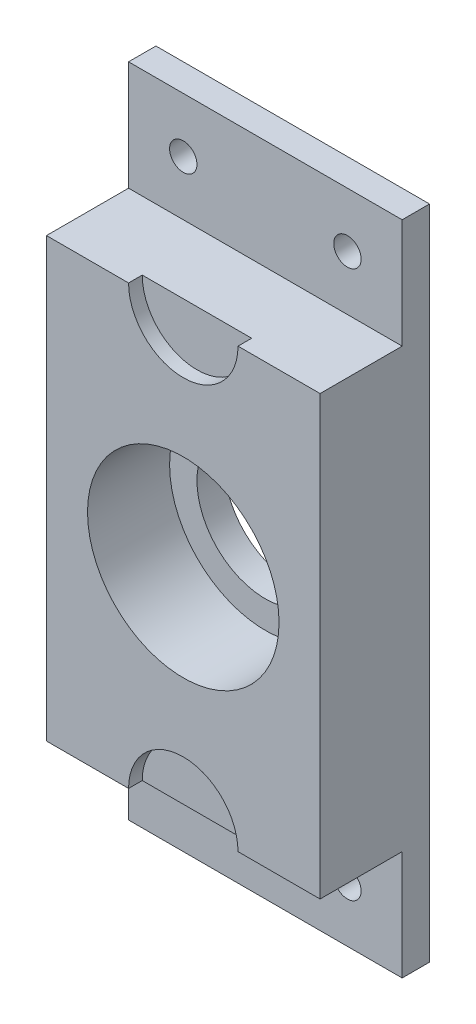
from build123d import *

# Parameters (mm, degrees)
BOSS_EXTRUDE1_DEPTH = 25.4
SKETCH2_W           = 63.5
SKETCH2_H           = 25.4
CUT_EXTRUDE1_DEPTH  = 19.05
SKETCH3_R           = 15.875
CUT_EXTRUDE4_DEPTH  = 26.4
SKETCH5_R           = 22.225
SKETCH5_R_2         = 15.875
CUT_EXTRUDE6_DEPTH  = 19.05
SKETCH6_R           = 12.7
CUT_EXTRUDE7_DEPTH  = 3.175
BOSS_EXTRUDE2_DEPTH = 25.4
SKETCH9_W           = 19.05
SKETCH9_H           = 3.556
BOSS_EXTRUDE4_DEPTH = 35.56


with BuildPart() as part:
    # Sketch1 → Boss-Extrude1 (new body)
    with BuildSketch(Plane.XY):
        with BuildLine():
            Line((-19.05, -66.675), (-19.05, -76.2))
            Line((-19.05, -76.2), (19.05, -76.2))
            Line((19.05, -76.2), (19.05, -66.675))
            ThreePointArc((19.05, -66.675), (16.80493597, -61.25493597), (22.225, -63.5))
            Line((22.225, -63.5), (31.75, -63.5))
            Line((31.75, -63.5), (31.75, 63.5))
            Line((31.75, 63.5), (22.225, 63.5))
            ThreePointArc((22.225, 63.5), (16.80493597, 61.25493597), (19.05, 66.675))
            Line((19.05, 66.675), (19.05, 76.2))
            Line((19.05, 76.2), (-19.05, 76.2))
            Line((-19.05, 76.2), (-19.05, 66.675))
            ThreePointArc((-19.05, 66.675), (-16.80493597, 65.74506403), (-15.875, 63.5))
            ThreePointArc((-15.875, 63.5), (-19.05, 60.325), (-22.225, 63.5))
            Line((-22.225, 63.5), (-31.75, 63.5))
            Line((-31.75, 63.5), (-31.75, -63.5))
            Line((-31.75, -63.5), (-22.225, -63.5))
            ThreePointArc((-22.225, -63.5), (-19.05, -60.325), (-15.875, -63.5))
            ThreePointArc((-15.875, -63.5), (-16.80493597, -65.74506403), (-19.05, -66.675))
        make_face()
        with BuildLine():
            Line((-31.75, 76.2), (-31.75, 63.5))
            Line((-31.75, 63.5), (-22.225, 63.5))
            ThreePointArc((-22.225, 63.5), (-21.29506403, 65.74506403), (-19.05, 66.675))
            Line((-19.05, 66.675), (-19.05, 76.2))
            Line((-19.05, 76.2), (-31.75, 76.2))
        make_face()
        with BuildLine():
            Line((22.225, 63.5), (31.75, 63.5))
            Line((31.75, 63.5), (31.75, 76.2))
            Line((31.75, 76.2), (19.05, 76.2))
            Line((19.05, 76.2), (19.05, 66.675))
            ThreePointArc((19.05, 66.675), (21.29506403, 65.74506403), (22.225, 63.5))
        make_face()
        with BuildLine():
            Line((-31.75, -63.5), (-31.75, -76.2))
            Line((-31.75, -76.2), (-19.05, -76.2))
            Line((-19.05, -76.2), (-19.05, -66.675))
            ThreePointArc((-19.05, -66.675), (-21.29506403, -65.74506403), (-22.225, -63.5))
            Line((-22.225, -63.5), (-31.75, -63.5))
        make_face()
        with BuildLine():
            Line((19.05, -66.675), (19.05, -76.2))
            Line((19.05, -76.2), (31.75, -76.2))
            Line((31.75, -76.2), (31.75, -63.5))
            Line((31.75, -63.5), (22.225, -63.5))
            ThreePointArc((22.225, -63.5), (21.29506403, -65.74506403), (19.05, -66.675))
        make_face()
    extrude(amount=BOSS_EXTRUDE1_DEPTH)

    # Sketch2 → Cut-Extrude1 (cut)
    with BuildSketch(Plane.XY.offset(25.4)):
        with Locations((0, 63.5)):
            Rectangle(SKETCH2_W, SKETCH2_H)
        with Locations((0, -63.5)):
            Rectangle(SKETCH2_W, SKETCH2_H)
    extrude(amount=-CUT_EXTRUDE1_DEPTH, mode=Mode.SUBTRACT)

    # Sketch3 → Cut-Extrude4 (cut, through all)
    with BuildSketch(Plane.XY.offset(25.4)):
        Circle(SKETCH3_R)
    extrude(amount=-CUT_EXTRUDE4_DEPTH, mode=Mode.SUBTRACT)

    # Sketch5 → Cut-Extrude6 (cut)
    with BuildSketch(Plane.XY.offset(25.4)):
        Circle(SKETCH5_R)
        Circle(SKETCH5_R_2, mode=Mode.SUBTRACT)
    extrude(amount=-CUT_EXTRUDE6_DEPTH, mode=Mode.SUBTRACT)

    # Sketch6 → Cut-Extrude7 (cut)
    with BuildSketch(Plane.XY.offset(25.4)):
        with Locations((0, -50.8)):
            Circle(SKETCH6_R)
        with Locations((0, 50.8)):
            Circle(SKETCH6_R)
    extrude(amount=-CUT_EXTRUDE7_DEPTH, mode=Mode.SUBTRACT)


with BuildPart() as body_2:
    # Sketch7 → Boss-Extrude2 (new body)
    with BuildSketch(Plane.ZY.offset(31.75)):
        Polygon((0, 123.19), (19.05, 123.19), (19.05, -50.8), (6.35, -50.8), (6.35, -76.2), (0, -76.2), align=None)
    extrude(amount=BOSS_EXTRUDE2_DEPTH)

    # Sketch9 → Boss-Extrude4 (add)
    with BuildSketch(Plane.ZY.offset(57.15)):
        with Locations((9.525, 121.412)):
            Rectangle(SKETCH9_W, SKETCH9_H)
        with Locations((9.525, 110.236)):
            Rectangle(SKETCH9_W, SKETCH9_H)
    extrude(amount=BOSS_EXTRUDE4_DEPTH)


solid = part.part
